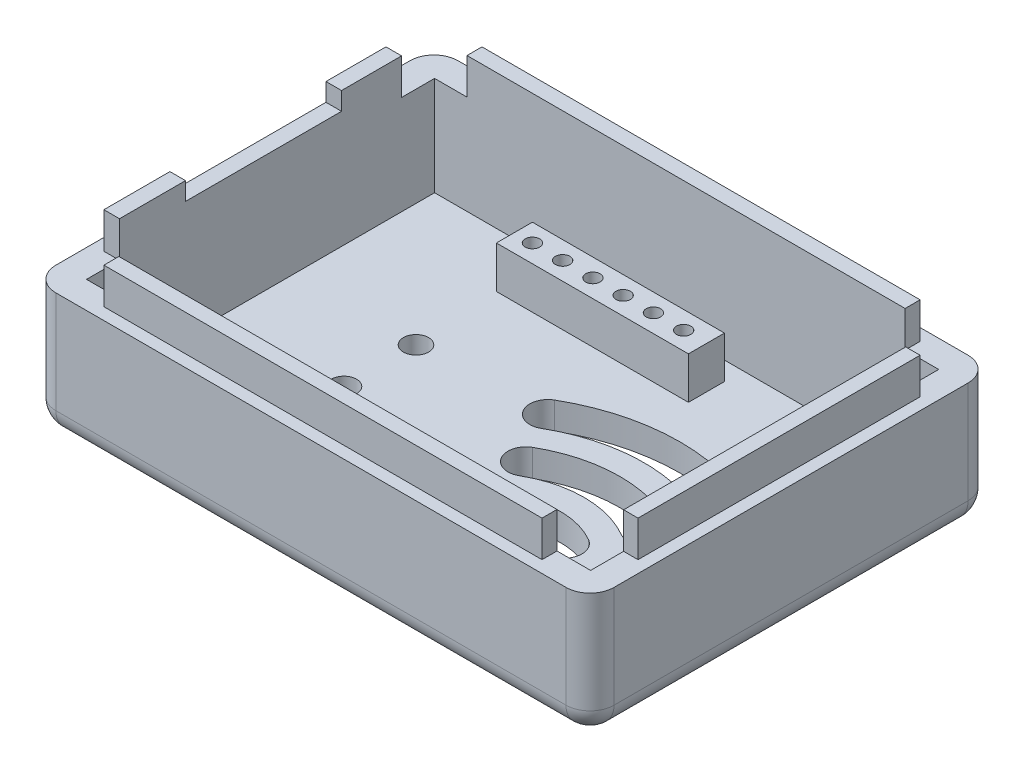
from build123d import *

# Parameters (mm, degrees)
SKETCH1_W               = 46.5
SKETCH1_H               = 33.5
BOSS_EXTRUDE1_DEPTH     = 13.5
SKETCH2_W               = 42
SKETCH2_H               = 29
CUT_EXTRUDE1_DEPTH      = 11.25
FILLET1_R               = 2
SKETCH4_R               = 1.05
CUT_EXTRUDE2_DEPTH      = 11.25
SKETCH6_R               = 1.5
CUT_EXTRUDE4_DEPTH      = 11.25
SKETCH7_R               = 2
CUT_EXTRUDE5_DEPTH      = 11.25
SKETCH8_W               = 16
SKETCH8_H               = 3
BOSS_EXTRUDE2_DEPTH     = 3.5
SKETCH9_R               = 0.6
CUT_EXTRUDE6_DEPTH      = 4.5
LPATTERN1_COUNT         = 6
LPATTERN1_PITCH         = 2.52
MIRROR1_COPY_1_SKETCH_R = 0.6
MIRROR1_COPY_1_DEPTH    = 4.5
MIRROR1_COPY_2_SKETCH_R = 0.6
MIRROR1_COPY_2_DEPTH    = 4.5
MIRROR1_COPY_3_SKETCH_R = 0.6
MIRROR1_COPY_3_DEPTH    = 4.5
MIRROR1_COPY_4_SKETCH_R = 0.6
MIRROR1_COPY_4_DEPTH    = 4.5
MIRROR1_COPY_5_SKETCH_R = 0.6
MIRROR1_COPY_5_DEPTH    = 4.5
SKETCH11_W              = 48.5
SKETCH11_H              = 35.5
SKETCH11_W_2            = 44.5
SKETCH11_H_2            = 31.5
CUT_EXTRUDE7_DEPTH      = 3
SKETCH12_W              = 4
SKETCH12_H              = 13
CUT_EXTRUDE8_DEPTH      = 1.5
SKETCH13_W              = 10
SKETCH13_H              = 10
CUT_EXTRUDE9_DEPTH      = 3
CUT_EXTRUDE3_DEPTH      = 10
CUT_EXTRUDE3_DEPTH_BACK = 11.25
SKETCH5_W               = 6.5
SKETCH5_H               = 4.5
FILLET2_R               = 5


with BuildPart() as part:
    # Sketch1 → Boss-Extrude1 (new body)
    with BuildSketch(Plane(origin=(0, 0, 0), x_dir=(1, 0, 0), z_dir=(0, 1, 0))):
        with Locations((-23.25, 16.75)):
            Rectangle(SKETCH1_W, SKETCH1_H)
    extrude(amount=BOSS_EXTRUDE1_DEPTH)

    # Sketch2 → Cut-Extrude1 (cut)
    with BuildSketch(Plane(origin=(0, 13.5, 0), x_dir=(1, 0, 0), z_dir=(0, 1, 0))):
        with Locations((-23.2, 16.75)):
            Rectangle(SKETCH2_W, SKETCH2_H)
    extrude(amount=-CUT_EXTRUDE1_DEPTH, mode=Mode.SUBTRACT)

    # Fillet1
    fillet1_edges = [part.edges().sort_by_distance(p)[0] for p in [
        (-46.5, 6.75, 0),
        (-46.5, 6.75, -33.5),
        (0, 6.75, -33.5),
        (0, 6.75, 0),
        (-46.5, 0, -16.75),
        (-23.25, 0, -33.5),
        (0, 0, -16.75),
        (-23.25, 0, 0),
    ]]
    fillet(fillet1_edges, radius=FILLET1_R)

    # Sketch4 → Cut-Extrude2 (cut)
    with BuildSketch(Plane(origin=(0, 2.25, 0), x_dir=(1, 0, 0), z_dir=(0, 1, 0))):
        with Locations((-34, 19.5)):
            Circle(SKETCH4_R)
        with Locations((-34, 13.5)):
            Circle(SKETCH4_R)
    extrude(amount=-CUT_EXTRUDE2_DEPTH, mode=Mode.SUBTRACT)

    # Sketch6 → Cut-Extrude4 (cut)
    with BuildSketch(Plane(origin=(0, 2.25, 0), x_dir=(1, 0, 0), z_dir=(0, 1, 0))):
        with BuildLine():
            ThreePointArc((-19.25, 12.629165125), (-19.799038106, 10.580127019), (-17.75, 10.031088913))
            ThreePointArc((-17.75, 10.031088913), (-16, 10.5), (-14.25, 10.031088913))
            ThreePointArc((-14.25, 10.031088913), (-12.200961894, 10.580127019), (-12.75, 12.629165125))
            ThreePointArc((-12.75, 12.629165125), (-16, 13.5), (-19.25, 12.629165125))
        make_face()
        with Locations((-16, 7)):
            Circle(SKETCH6_R)
        with BuildLine():
            ThreePointArc((-21.75, 16.959292144), (-22.299038106, 14.910254038), (-20.25, 14.361215932))
            ThreePointArc((-20.25, 14.361215932), (-16, 15.5), (-11.75, 14.361215932))
            ThreePointArc((-11.75, 14.361215932), (-9.700961894, 14.910254038), (-10.25, 16.959292144))
            ThreePointArc((-10.25, 16.959292144), (-16, 18.5), (-21.75, 16.959292144))
        make_face()
        with BuildLine():
            ThreePointArc((-24.25, 21.289419162), (-24.799038106, 19.240381057), (-22.75, 18.691342951))
            ThreePointArc((-22.75, 18.691342951), (-16, 20.5), (-9.25, 18.691342951))
            ThreePointArc((-9.25, 18.691342951), (-7.200961894, 19.240381057), (-7.75, 21.289419162))
            ThreePointArc((-7.75, 21.289419162), (-16, 23.5), (-24.25, 21.289419162))
        make_face()
    extrude(amount=-CUT_EXTRUDE4_DEPTH, mode=Mode.SUBTRACT)

    # Sketch7 → Cut-Extrude5 (cut)
    with BuildSketch(Plane(origin=(0, 2.25, 0), x_dir=(1, 0, 0), z_dir=(0, 1, 0))):
        with Locations((-40.25, 9)):
            Circle(SKETCH7_R)
    extrude(amount=-CUT_EXTRUDE5_DEPTH, mode=Mode.SUBTRACT)

    # Sketch8 → Boss-Extrude2 (add)
    with BuildSketch(Plane(origin=(0, 2.25, 0), x_dir=(1, 0, 0), z_dir=(0, 1, 0))):
        with Locations((-26.5, 5.3)):
            Rectangle(SKETCH8_W, SKETCH8_H)
    boss_extrude2 = extrude(amount=BOSS_EXTRUDE2_DEPTH)

    # Sketch9 → Cut-Extrude6 (cut)
    with BuildSketch(Plane(origin=(0, 5.75, 0), x_dir=(1, 0, 0), z_dir=(0, 1, 0))):
        with Locations((-33, 5.3)):
            Circle(SKETCH9_R)
    cut_extrude6 = extrude(amount=-CUT_EXTRUDE6_DEPTH, mode=Mode.SUBTRACT)

    # LPattern1: Cut-Extrude6 ×6
    with Locations(*[(i * LPATTERN1_PITCH, 0, 0) for i in range(1, LPATTERN1_COUNT)]):
        add(cut_extrude6, mode=Mode.SUBTRACT)

    # Mirror1: Boss-Extrude2, Cut-Extrude6 across plane
    add(boss_extrude2.mirror(Plane.XY.offset(-16.75)))
    add(cut_extrude6.mirror(Plane.XY.offset(-16.75)), mode=Mode.SUBTRACT)

    # Mirror1 copy 1 sketch → Mirror1 copy 1 (cut)
    with BuildSketch(Plane(origin=(2.52, 5.75, -33.5), x_dir=(1, 0, 0), z_dir=(0, 1, 0))):
        with Locations((-33, -5.3)):
            Circle(MIRROR1_COPY_1_SKETCH_R)
    extrude(amount=-MIRROR1_COPY_1_DEPTH, mode=Mode.SUBTRACT)

    # Mirror1 copy 2 sketch → Mirror1 copy 2 (cut)
    with BuildSketch(Plane(origin=(5.04, 5.75, -33.5), x_dir=(1, 0, 0), z_dir=(0, 1, 0))):
        with Locations((-33, -5.3)):
            Circle(MIRROR1_COPY_2_SKETCH_R)
    extrude(amount=-MIRROR1_COPY_2_DEPTH, mode=Mode.SUBTRACT)

    # Mirror1 copy 3 sketch → Mirror1 copy 3 (cut)
    with BuildSketch(Plane(origin=(7.56, 5.75, -33.5), x_dir=(1, 0, 0), z_dir=(0, 1, 0))):
        with Locations((-33, -5.3)):
            Circle(MIRROR1_COPY_3_SKETCH_R)
    extrude(amount=-MIRROR1_COPY_3_DEPTH, mode=Mode.SUBTRACT)

    # Mirror1 copy 4 sketch → Mirror1 copy 4 (cut)
    with BuildSketch(Plane(origin=(10.08, 5.75, -33.5), x_dir=(1, 0, 0), z_dir=(0, 1, 0))):
        with Locations((-33, -5.3)):
            Circle(MIRROR1_COPY_4_SKETCH_R)
    extrude(amount=-MIRROR1_COPY_4_DEPTH, mode=Mode.SUBTRACT)

    # Mirror1 copy 5 sketch → Mirror1 copy 5 (cut)
    with BuildSketch(Plane(origin=(12.6, 5.75, -33.5), x_dir=(1, 0, 0), z_dir=(0, 1, 0))):
        with Locations((-33, -5.3)):
            Circle(MIRROR1_COPY_5_SKETCH_R)
    extrude(amount=-MIRROR1_COPY_5_DEPTH, mode=Mode.SUBTRACT)

    # Sketch11 → Cut-Extrude7 (cut)
    with BuildSketch(Plane(origin=(0, 13.5, 0), x_dir=(1, 0, 0), z_dir=(0, 1, 0))):
        with Locations((-23.25, 16.75)):
            Rectangle(SKETCH11_W, SKETCH11_H)
        with Locations((-23.25, 16.75)):
            Rectangle(SKETCH11_W_2, SKETCH11_H_2, mode=Mode.SUBTRACT)
    extrude(amount=-CUT_EXTRUDE7_DEPTH, mode=Mode.SUBTRACT)

    # Sketch12 → Cut-Extrude8 (cut)
    with BuildSketch(Plane(origin=(0, 13.5, 0), x_dir=(1, 0, 0), z_dir=(0, 1, 0))):
        with Locations((-45, 17)):
            Rectangle(SKETCH12_W, SKETCH12_H)
    extrude(amount=-CUT_EXTRUDE8_DEPTH, mode=Mode.SUBTRACT)

    # Sketch13 → Cut-Extrude9 (cut)
    with BuildSketch(Plane(origin=(0, 13.5, 0), x_dir=(1, 0, 0), z_dir=(0, 1, 0))):
        Rectangle(SKETCH13_W, SKETCH13_H)
        with Locations((0, 33.5)):
            Rectangle(SKETCH13_W, SKETCH13_H)
        with Locations((-46.5, 33.5)):
            Rectangle(SKETCH13_W, SKETCH13_H)
        with Locations((-46.5, 0)):
            Rectangle(SKETCH13_W, SKETCH13_H)
    extrude(amount=-CUT_EXTRUDE9_DEPTH, mode=Mode.SUBTRACT)

    # Sketch5 → Cut-Extrude3 (cut, two sides: drawn at the far end of the back side and taken through both)
    with BuildSketch(Plane(origin=(0, 2.25, 0), x_dir=(1, 0, 0), z_dir=(0, 1, 0)).offset(-CUT_EXTRUDE3_DEPTH_BACK)):
        with Locations((-37.25, 5.5)):
            Rectangle(SKETCH5_W, SKETCH5_H)
    extrude(amount=CUT_EXTRUDE3_DEPTH + CUT_EXTRUDE3_DEPTH_BACK, mode=Mode.SUBTRACT)

    # Fillet2
    fillet2_edges = [part.edges().sort_by_distance(p)[0] for p in [
        (-40.5, 1.125, -7.015686517),
        (-38.6887505, 1.125, -7.75),
    ]]
    fillet(fillet2_edges, radius=FILLET2_R)


solid = part.part
